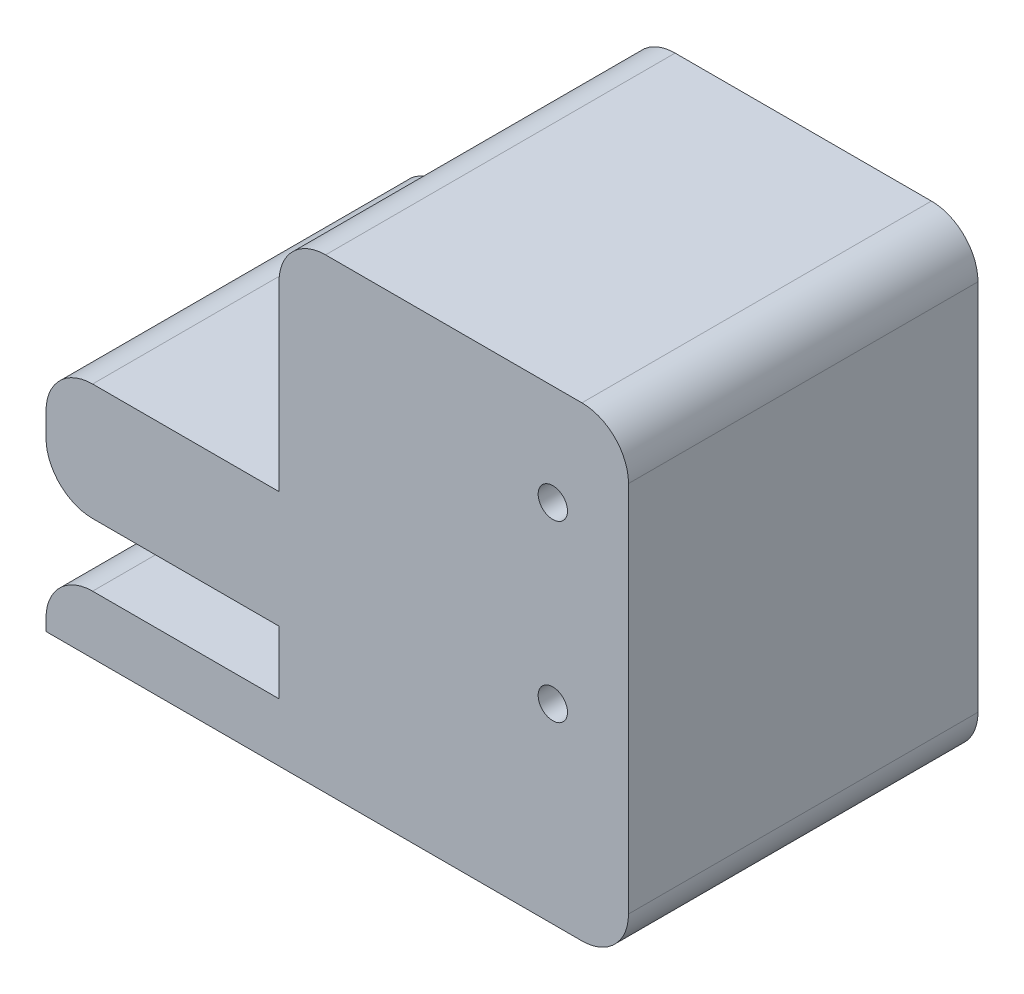
from build123d import *

# Parameters (mm, degrees)
BOSS_EXTRUDE1_DEPTH       = 19.05
M4X0_7_TAPPED_HOLE1_D     = 3.3
M4X0_7_TAPPED_HOLE1_DEPTH = 6.35
M2X0_4_TAPPED_HOLE1_D     = 1.6
M2X0_4_TAPPED_HOLE1_DEPTH = 19.05
FILLET1_R                 = 2.54


with BuildPart() as part:
    # Sketch1 → Boss-Extrude1 (new body)
    with BuildSketch(Plane.XY):
        Polygon((0, 0), (12.7, 0), (12.7, -3.429), (0, -3.429), (0, -6.604), (31.75, -6.604), (31.75, 18.796), (12.7, 18.796), (12.7, 6.35), (0, 6.35), align=None)
    extrude(amount=BOSS_EXTRUDE1_DEPTH)

    # M4x0.7 Tapped Hole1
    with Locations(Plane(origin=(0, 6.35, 0), x_dir=(1, 0, 0), z_dir=(0, 1, 0))):
        with Locations((6.35, -9.525)):
            Hole(M4X0_7_TAPPED_HOLE1_D / 2, depth=M4X0_7_TAPPED_HOLE1_DEPTH)

    # M2x0.4 Tapped Hole1
    with Locations(Plane.XY.offset(19.05)):
        with Locations((27.625, 13.296), (27.625, 3.796)):
            Hole(M2X0_4_TAPPED_HOLE1_D / 2, depth=M2X0_4_TAPPED_HOLE1_DEPTH)

    # Fillet1
    fillet1_edges = [part.edges().sort_by_distance(p)[0] for p in [
        (0, 6.35, 9.525),
        (12.7, 18.796, 9.525),
        (31.75, 18.796, 9.525),
        (31.75, -6.604, 9.525),
        (0, -3.429, 9.525),
        (0, 0, 9.525),
    ]]
    fillet(fillet1_edges, radius=FILLET1_R)


solid = part.part
